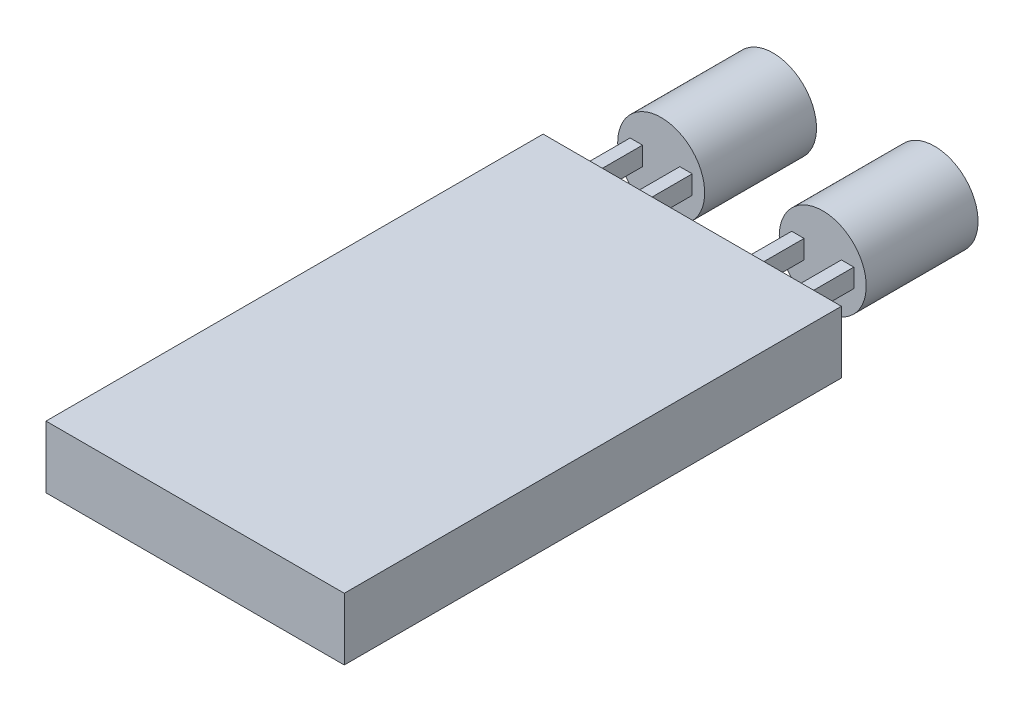
from build123d import *

# Parameters (mm, degrees)
SKETCH1_W           = 24
SKETCH1_H           = 40
BOSS_EXTRUDE1_DEPTH = 5
SKETCH2_W           = 1
SKETCH2_H           = 1.5
BOSS_EXTRUDE2_DEPTH = 4
SKETCH4_R           = 3.5
BOSS_EXTRUDE4_DEPTH = 9


with BuildPart() as part:
    # Sketch1 → Boss-Extrude1 (new body)
    with BuildSketch(Plane(origin=(0, 0, 0), x_dir=(1, 0, 0), z_dir=(0, 1, 0))):
        with Locations((-12, -10.571428571)):
            Rectangle(SKETCH1_W, SKETCH1_H)
    extrude(amount=BOSS_EXTRUDE1_DEPTH)

    # Sketch2 → Boss-Extrude2 (add)
    with BuildSketch(Plane(origin=(0, 0, -9.428571429), x_dir=(-1, 0, 0), z_dir=(0, 0, -1))):
        with Locations((3.5, 3.479518838)):
            Rectangle(SKETCH2_W, SKETCH2_H)
        with Locations((7.5, 3.479518838)):
            Rectangle(SKETCH2_W, SKETCH2_H)
        with Locations((16.5, 3.479518838)):
            Rectangle(SKETCH2_W, SKETCH2_H)
        with Locations((20.5, 3.479518838)):
            Rectangle(SKETCH2_W, SKETCH2_H)
    extrude(amount=BOSS_EXTRUDE2_DEPTH)

    # Sketch4 → Boss-Extrude4 (add)
    with BuildSketch(Plane(origin=(0, 0, -13.428571429), x_dir=(-1, 0, 0), z_dir=(0, 0, -1))):
        with Locations((5.5, 3.40608753)):
            Circle(SKETCH4_R)
        with Locations((18.5, 3.40608753)):
            Circle(SKETCH4_R)
    extrude(amount=BOSS_EXTRUDE4_DEPTH)


solid = part.part
